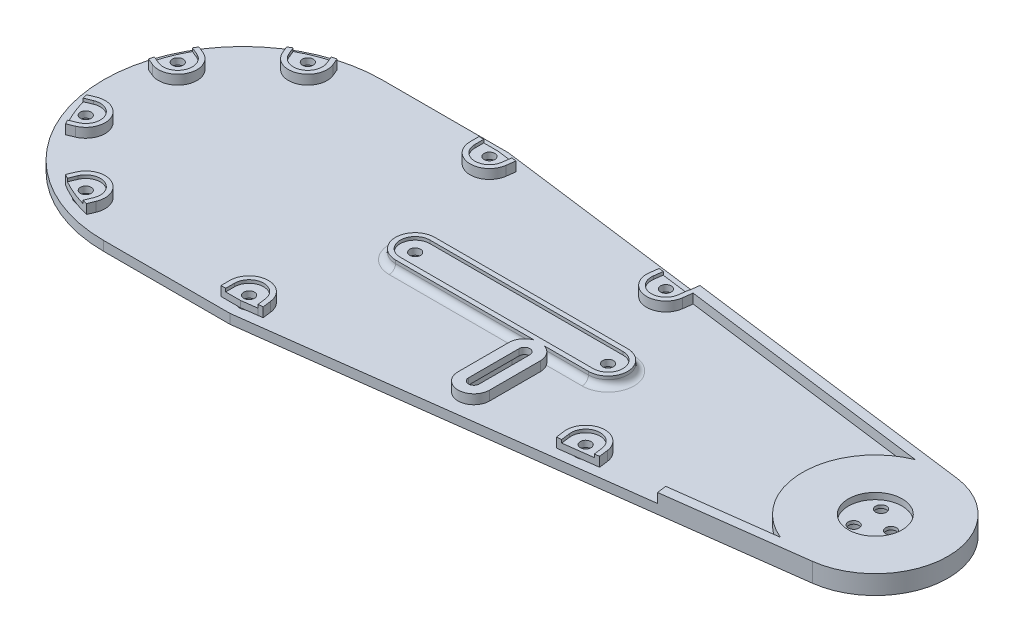
from build123d import *

# Parameters (mm, degrees)
SKETCH1_R               = 1.7
BOSS_EXTRUDE1_DEPTH     = 3
BOSS_EXTRUDE2_DEPTH     = 3
SKETCH3_R               = 1.7
BOSS_EXTRUDE3_DEPTH     = 2
SKETCH4_R               = 3
CUT_EXTRUDE1_DEPTH      = 3
SKETCH5_R               = 8.5
CUT_EXTRUDE2_DEPTH      = 1
SKETCH6_R               = 8.5
BOSS_EXTRUDE4_DEPTH     = 3
BOSS_EXTRUDE6_DEPTH     = 3
FILLET2_R               = 2
BOSS_EXTRUDE7_DEPTH     = 2
SKETCH9_R               = 1.7
CUT_EXTRUDE3_DEPTH      = 4
CUT_EXTRUDE3_DEPTH_BACK = 4
SKETCH11_R              = 3
CUT_EXTRUDE4_DEPTH      = 3
SKETCH12_R              = 8.5
BOSS_EXTRUDE8_DEPTH     = 2
CUT_EXTRUDE5_REACH      = 6
SKETCH13_R              = 1.7
SKETCH14_R              = 3
CUT_EXTRUDE6_DEPTH      = 3
CUT_EXTRUDE7_DEPTH      = 4
BOSS_EXTRUDE9_DEPTH     = 3
CUT_EXTRUDE8_DEPTH      = 4


with BuildPart() as part:
    # Sketch1 → Boss-Extrude1 (new body)
    with BuildSketch(Plane(origin=(0, 0, 0), x_dir=(1, 0, 0), z_dir=(0, 1, 0))):
        with BuildLine():
            Line((0, 44), (40, 44))
            Line((40, 44), (202.965939969, 22.807963524))
            ThreePointArc((202.965939969, 22.807963524), (223, 0), (202.965939969, -22.807963524))
            Line((202.965939969, -22.807963524), (40, -44))
            Line((40, -44), (0, -44))
            ThreePointArc((0, -44), (-44, 0), (0, 44))
        make_face()
        with Locations((-35.107422235, 14.54197043)):
            Circle(SKETCH1_R, mode=Mode.SUBTRACT)
        with Locations((-14.54197043, 35.107422235)):
            Circle(SKETCH1_R, mode=Mode.SUBTRACT)
        with Locations((-14.54197043, -35.107422235)):
            Circle(SKETCH1_R, mode=Mode.SUBTRACT)
        with Locations((-35.107422235, -14.54197043)):
            Circle(SKETCH1_R, mode=Mode.SUBTRACT)
        with Locations((40, 38)):
            Circle(SKETCH1_R, mode=Mode.SUBTRACT)
        with Locations((40, -38)):
            Circle(SKETCH1_R, mode=Mode.SUBTRACT)
        with Locations((134.1272378, -25.709207123)):
            Circle(SKETCH1_R, mode=Mode.SUBTRACT)
        with Locations((104.179390043, 29.603615256)):
            Circle(SKETCH1_R, mode=Mode.SUBTRACT)
    extrude(amount=BOSS_EXTRUDE1_DEPTH)

    # Sketch2 → Boss-Extrude2 (add)
    with BuildSketch(Plane(origin=(0, 3, 0), x_dir=(1, 0, 0), z_dir=(0, 1, 0))):
        with BuildLine():
            Line((-33.347078447, 18.791816279), (-35.693600281, 19.763777448))
            ThreePointArc((-35.693600281, 19.763777448), (-35.320993476, 20.422228573), (-34.936241394, 21.073657425))
            Line((-34.936241394, 21.073657425), (-32.773053298, 20.177635578))
            ThreePointArc((-32.773053298, 20.177635578), (-29.471757087, 12.207601492), (-37.441791173, 8.906305282))
            Line((-37.441791173, 8.906305282), (-39.604979269, 9.802327129))
            ThreePointArc((-39.604979269, 9.802327129), (-39.416410316, 10.535017694), (-39.214287859, 11.264085748))
            Line((-39.214287859, 11.264085748), (-36.867766024, 10.29212458))
            ThreePointArc((-36.867766024, 10.29212458), (-30.857576386, 12.781626641), (-33.347078447, 18.791816279))
        make_face()
        with BuildLine():
            Line((-20.177635578, 32.773053298), (-21.073657425, 34.936241394))
            ThreePointArc((-21.073657425, 34.936241394), (-20.422228573, 35.320993476), (-19.763777448, 35.693600281))
            Line((-19.763777448, 35.693600281), (-18.791816279, 33.347078447))
            ThreePointArc((-18.791816279, 33.347078447), (-12.781626641, 30.857576386), (-10.29212458, 36.867766024))
            Line((-10.29212458, 36.867766024), (-11.264085748, 39.214287859))
            ThreePointArc((-11.264085748, 39.214287859), (-10.535017694, 39.416410316), (-9.802327129, 39.604979269))
            Line((-9.802327129, 39.604979269), (-8.906305282, 37.441791173))
            ThreePointArc((-8.906305282, 37.441791173), (-12.207601492, 29.471757087), (-20.177635578, 32.773053298))
        make_face()
        with BuildLine():
            Line((-8.906305282, -37.441791173), (-9.802327129, -39.604979269))
            ThreePointArc((-9.802327129, -39.604979269), (-10.535017694, -39.416410316), (-11.264085748, -39.214287859))
            Line((-11.264085748, -39.214287859), (-10.29212458, -36.867766024))
            ThreePointArc((-10.29212458, -36.867766024), (-12.781626641, -30.857576386), (-18.791816279, -33.347078447))
            Line((-18.791816279, -33.347078447), (-19.763777448, -35.693600281))
            ThreePointArc((-19.763777448, -35.693600281), (-20.422228573, -35.320993476), (-21.073657425, -34.936241394))
            Line((-21.073657425, -34.936241394), (-20.177635578, -32.773053298))
            ThreePointArc((-20.177635578, -32.773053298), (-12.207601492, -29.471757087), (-8.906305282, -37.441791173))
        make_face()
        with BuildLine():
            Line((-32.773053298, -20.177635578), (-34.936241394, -21.073657425))
            ThreePointArc((-34.936241394, -21.073657425), (-35.320993476, -20.422228573), (-35.693600281, -19.763777448))
            Line((-35.693600281, -19.763777448), (-33.347078447, -18.791816279))
            ThreePointArc((-33.347078447, -18.791816279), (-30.857576386, -12.781626641), (-36.867766024, -10.29212458))
            Line((-36.867766024, -10.29212458), (-39.214287859, -11.264085748))
            ThreePointArc((-39.214287859, -11.264085748), (-39.416410316, -10.535017694), (-39.604979269, -9.802327129))
            Line((-39.604979269, -9.802327129), (-37.441791173, -8.906305282))
            ThreePointArc((-37.441791173, -8.906305282), (-29.471757087, -12.207601492), (-32.773053298, -20.177635578))
        make_face()
        with BuildLine():
            Line((44.561592705, 37.406812006), (44.916203521, 40.133755457))
            Line((44.916203521, 40.133755457), (46.403679403, 39.940324589))
            Line((46.403679403, 39.940324589), (46.049068587, 37.213381139))
            ThreePointArc((46.049068587, 37.213381139), (39.605867014, 31.91274617), (33.9, 38))
            Line((33.9, 38), (33.9, 40.8))
            Line((33.9, 40.8), (35.4, 40.8))
            Line((35.4, 40.8), (35.4, 38))
            ThreePointArc((35.4, 38), (39.702784962, 33.409611866), (44.561592705, 37.406812006))
        make_face()
        with BuildLine():
            Line((99.617797338, 30.19680325), (99.978868291, 32.973424896))
            Line((99.978868291, 32.973424896), (98.491392409, 33.166855764))
            Line((98.491392409, 33.166855764), (98.130321456, 30.390234117))
            ThreePointArc((98.130321456, 30.390234117), (103.392771182, 23.554546669), (110.22845863, 28.816996395))
            Line((110.22845863, 28.816996395), (110.589529583, 31.593618041))
            Line((110.589529583, 31.593618041), (109.102053701, 31.787048908))
            Line((109.102053701, 31.787048908), (108.740982748, 29.010427262))
            ThreePointArc((108.740982748, 29.010427262), (103.586202049, 25.042022551), (99.617797338, 30.19680325))
        make_face()
        with BuildLine():
            Line((129.565645096, -26.302395116), (129.926716048, -29.079016763))
            Line((129.926716048, -29.079016763), (128.439240166, -29.27244763))
            Line((128.439240166, -29.27244763), (128.078169214, -26.495825984))
            ThreePointArc((128.078169214, -26.495825984), (133.340618939, -19.660138536), (140.176306387, -24.922588261))
            Line((140.176306387, -24.922588261), (140.53737734, -27.699209908))
            Line((140.53737734, -27.699209908), (139.049901458, -27.892640775))
            Line((139.049901458, -27.892640775), (138.688830505, -25.116019129))
            ThreePointArc((138.688830505, -25.116019129), (133.534049807, -21.147614418), (129.565645096, -26.302395116))
        make_face()
        with BuildLine():
            Line((44.561592705, -37.406812006), (44.916203521, -40.133755457))
            Line((44.916203521, -40.133755457), (46.403679403, -39.940324589))
            Line((46.403679403, -39.940324589), (46.049068587, -37.213381139))
            ThreePointArc((46.049068587, -37.213381139), (39.605867014, -31.91274617), (33.9, -38))
            Line((33.9, -38), (33.9, -40.8))
            Line((33.9, -40.8), (35.4, -40.8))
            Line((35.4, -40.8), (35.4, -38))
            ThreePointArc((35.4, -38), (39.702784962, -33.409611866), (44.561592705, -37.406812006))
        make_face()
    extrude(amount=BOSS_EXTRUDE2_DEPTH)

    # Sketch3 → Boss-Extrude3 (add)
    with BuildSketch(Plane(origin=(0, 3, 0), x_dir=(1, 0, 0), z_dir=(0, 1, 0))):
        with BuildLine():
            Line((-36.867766024, 10.29212458), (-39.214287859, 11.264085748))
            ThreePointArc((-39.214287859, 11.264085748), (-37.694284926, 15.61348404), (-35.693600281, 19.763777448))
            Line((-35.693600281, 19.763777448), (-33.347078447, 18.791816279))
            ThreePointArc((-33.347078447, 18.791816279), (-30.857576386, 12.781626641), (-36.867766024, 10.29212458))
        make_face()
        with Locations((-35.107422235, 14.54197043)):
            Circle(SKETCH3_R, mode=Mode.SUBTRACT)
        with BuildLine():
            Line((-11.264085748, 39.214287859), (-10.29212458, 36.867766024))
            ThreePointArc((-10.29212458, 36.867766024), (-12.781626641, 30.857576386), (-18.791816279, 33.347078447))
            Line((-18.791816279, 33.347078447), (-19.763777448, 35.693600281))
            ThreePointArc((-19.763777448, 35.693600281), (-15.61348404, 37.694284926), (-11.264085748, 39.214287859))
        make_face()
        with Locations((-14.54197043, 35.107422235)):
            Circle(SKETCH3_R, mode=Mode.SUBTRACT)
        with BuildLine():
            Line((-19.763777448, -35.693600281), (-18.791816279, -33.347078447))
            ThreePointArc((-18.791816279, -33.347078447), (-12.781626641, -30.857576386), (-10.29212458, -36.867766024))
            Line((-10.29212458, -36.867766024), (-11.264085748, -39.214287859))
            ThreePointArc((-11.264085748, -39.214287859), (-15.61348404, -37.694284926), (-19.763777448, -35.693600281))
        make_face()
        with Locations((-14.54197043, -35.107422235)):
            Circle(SKETCH3_R, mode=Mode.SUBTRACT)
        with BuildLine():
            Line((-39.214287859, -11.264085748), (-36.867766024, -10.29212458))
            ThreePointArc((-36.867766024, -10.29212458), (-30.857576386, -12.781626641), (-33.347078447, -18.791816279))
            Line((-33.347078447, -18.791816279), (-35.693600281, -19.763777448))
            ThreePointArc((-35.693600281, -19.763777448), (-37.694284926, -15.61348404), (-39.214287859, -11.264085748))
        make_face()
        with Locations((-35.107422235, -14.54197043)):
            Circle(SKETCH3_R, mode=Mode.SUBTRACT)
        with BuildLine():
            Line((138.688830505, -25.116019129), (139.049901458, -27.892640775))
            Line((139.049901458, -27.892640775), (129.926716048, -29.079016763))
            Line((129.926716048, -29.079016763), (129.565645096, -26.302395116))
            ThreePointArc((129.565645096, -26.302395116), (133.534049807, -21.147614418), (138.688830505, -25.116019129))
        make_face()
        with Locations((134.1272378, -25.709207123)):
            Circle(SKETCH3_R, mode=Mode.SUBTRACT)
        with BuildLine():
            Line((109.102053701, 31.787048908), (108.740982748, 29.010427262))
            ThreePointArc((108.740982748, 29.010427262), (103.586202049, 25.042022551), (99.617797338, 30.19680325))
            Line((99.617797338, 30.19680325), (99.978868291, 32.973424896))
            Line((99.978868291, 32.973424896), (109.102053701, 31.787048908))
        make_face()
        with Locations((104.179390043, 29.603615256)):
            Circle(SKETCH3_R, mode=Mode.SUBTRACT)
        with BuildLine():
            Line((44.561592705, -37.406812006), (44.916203521, -40.133755457))
            Line((44.916203521, -40.133755457), (40, -40.8))
            Line((40, -40.8), (35.4, -40.8))
            Line((35.4, -40.8), (35.4, -38))
            ThreePointArc((35.4, -38), (39.702784962, -33.409611866), (44.561592705, -37.406812006))
        make_face()
        with Locations((40, -38)):
            Circle(SKETCH3_R, mode=Mode.SUBTRACT)
        with BuildLine():
            Line((44.916203521, 40.133755457), (44.561592705, 37.406812006))
            ThreePointArc((44.561592705, 37.406812006), (39.702784962, 33.409611866), (35.4, 38))
            Line((35.4, 38), (35.4, 40.8))
            Line((35.4, 40.8), (40, 40.8))
            Line((40, 40.8), (44.916203521, 40.133755457))
        make_face()
        with Locations((40, 38)):
            Circle(SKETCH3_R, mode=Mode.SUBTRACT)
    extrude(amount=BOSS_EXTRUDE3_DEPTH)

    # Sketch4 → Cut-Extrude1 (cut)
    with BuildSketch(Plane.XZ):
        with Locations((-14.54197043, 35.107422235)):
            Circle(SKETCH4_R)
        with Locations((-35.107422235, 14.54197043)):
            Circle(SKETCH4_R)
        with Locations((-35.107422235, -14.54197043)):
            Circle(SKETCH4_R)
        with Locations((-14.54197043, -35.107422235)):
            Circle(SKETCH4_R)
        with Locations((40, 38)):
            Circle(SKETCH4_R)
        with Locations((134.1272378, 25.709207123)):
            Circle(SKETCH4_R)
        with Locations((104.179390043, -29.603615256)):
            Circle(SKETCH4_R)
        with Locations((40, -38)):
            Circle(SKETCH4_R)
    extrude(amount=-CUT_EXTRUDE1_DEPTH, mode=Mode.SUBTRACT)

    # Sketch5 → Cut-Extrude2 (cut)
    with BuildSketch(Plane(origin=(0, 3, 0), x_dir=(1, 0, 0), z_dir=(0, 1, 0))):
        with Locations((200, 0)):
            Circle(SKETCH5_R)
    extrude(amount=-CUT_EXTRUDE2_DEPTH, mode=Mode.SUBTRACT)

    # Sketch6 → Boss-Extrude4 (add)
    with BuildSketch(Plane(origin=(0, 3, 0), x_dir=(1, 0, 0), z_dir=(0, 1, 0))):
        with BuildLine():
            Line((159.585349939, -28.449160982), (159.198488204, -25.474209218))
            Line((159.198488204, -25.474209218), (191.316092633, -21.29764665))
            ThreePointArc((191.316092633, -21.29764665), (177, 0), (191.316092633, 21.29764665))
            Line((191.316092633, 21.29764665), (110.615320365, 31.791948159))
            Line((110.615320365, 31.791948159), (110.589529583, 31.593618041))
            Line((110.589529583, 31.593618041), (109.102053701, 31.787048908))
            Line((109.102053701, 31.787048908), (109.127844483, 31.985379026))
            Line((109.127844483, 31.985379026), (109.227009542, 31.972483635))
            Line((109.227009542, 31.972483635), (109.613871277, 34.947435399))
            Line((109.613871277, 34.947435399), (202.965939969, 22.807963524))
            ThreePointArc((202.965939969, 22.807963524), (223, 0), (202.965939969, -22.807963524))
            Line((202.965939969, -22.807963524), (159.585349939, -28.449160982))
        make_face()
        with Locations((200, 0)):
            Circle(SKETCH6_R, mode=Mode.SUBTRACT)
    extrude(amount=BOSS_EXTRUDE4_DEPTH)

    # Sketch8 → Boss-Extrude6 (add)
    with BuildSketch(Plane(origin=(0, 3, 0), x_dir=(1, 0, 0), z_dir=(0, 1, 0))):
        with BuildLine():
            Line((54.5, 6.2), (115.5, 6.2))
            ThreePointArc((115.5, 6.2), (121.7, 0), (115.5, -6.2))
            Line((115.5, -6.2), (54.5, -6.2))
            ThreePointArc((54.5, -6.2), (48.3, 0), (54.5, 6.2))
        make_face()
        with BuildLine():
            Line((54.5, 4.7), (115.5, 4.7))
            ThreePointArc((115.5, 4.7), (120.2, 0), (115.5, -4.7))
            Line((115.5, -4.7), (54.5, -4.7))
            ThreePointArc((54.5, -4.7), (49.8, 0), (54.5, 4.7))
        make_face(mode=Mode.SUBTRACT)
    extrude(amount=BOSS_EXTRUDE6_DEPTH)

    # Fillet2
    fillet2_edges = [part.edges().sort_by_distance(p)[0] for p in [
        (48.3, 3, 0),
        (85, 3, 6.2),
        (121.7, 3, 0),
        (85, 3, -6.2),
    ]]
    fillet(fillet2_edges, radius=FILLET2_R)

    # Sketch10 → Boss-Extrude7 (add)
    with BuildSketch(Plane(origin=(0, 3, 0), x_dir=(1, 0, 0), z_dir=(0, 1, 0))):
        with BuildLine():
            Line((54.5, -4.7), (115.5, -4.7))
            ThreePointArc((115.5, -4.7), (120.2, 0), (115.5, 4.7))
            Line((115.5, 4.7), (54.5, 4.7))
            ThreePointArc((54.5, 4.7), (49.8, 0), (54.5, -4.7))
        make_face()
    extrude(amount=BOSS_EXTRUDE7_DEPTH)

    # Sketch9 → Cut-Extrude3 (cut, two sides)
    with BuildSketch(Plane(origin=(0, 3, 0), x_dir=(1, 0, 0), z_dir=(0, 1, 0))) as cut_extrude3_sk:
        with Locations((54.5, 0)):
            Circle(SKETCH9_R)
        with Locations((115.5, 0)):
            Circle(SKETCH9_R)
    extrude(amount=CUT_EXTRUDE3_DEPTH, mode=Mode.SUBTRACT)
    extrude(cut_extrude3_sk.sketch, amount=-CUT_EXTRUDE3_DEPTH_BACK, mode=Mode.SUBTRACT)

    # Sketch11 → Cut-Extrude4 (cut)
    with BuildSketch(Plane.XZ):
        with Locations((54.5, 0)):
            Circle(SKETCH11_R)
        with Locations((115.5, 0)):
            Circle(SKETCH11_R)
    extrude(amount=-CUT_EXTRUDE4_DEPTH, mode=Mode.SUBTRACT)

    # Sketch12 → Boss-Extrude8 (add)
    with BuildSketch(Plane(origin=(0, 2, 0), x_dir=(1, 0, 0), z_dir=(0, 1, 0))):
        with Locations((200, 0)):
            Circle(SKETCH12_R)
    extrude(amount=BOSS_EXTRUDE8_DEPTH)

    # Sketch13 → Cut-Extrude5 (cut, up to next)
    with BuildSketch(Plane(origin=(0, 4, 0), x_dir=(1, 0, 0), z_dir=(0, 1, 0)), mode=Mode.PRIVATE) as cut_extrude5_sk1:
        with Locations((205, 0)):
            Circle(SKETCH13_R)
    cut_extrude5_tool1 = extrude(cut_extrude5_sk1.sketch, amount=-CUT_EXTRUDE5_REACH, mode=Mode.PRIVATE) & part.part
    add(cut_extrude5_tool1.solids().sort_by_distance((205, 4, 0))[0], mode=Mode.SUBTRACT)
    # Sketch13 → Cut-Extrude5 (cut, up to next)
    with BuildSketch(Plane(origin=(0, 4, 0), x_dir=(1, 0, 0), z_dir=(0, 1, 0)), mode=Mode.PRIVATE) as cut_extrude5_sk2:
        with Locations((197.5, -4.330127019)):
            Circle(SKETCH13_R)
    cut_extrude5_tool2 = extrude(cut_extrude5_sk2.sketch, amount=-CUT_EXTRUDE5_REACH, mode=Mode.PRIVATE) & part.part
    add(cut_extrude5_tool2.solids().sort_by_distance((197.5, 4, 4.330127))[0], mode=Mode.SUBTRACT)
    # Sketch13 → Cut-Extrude5 (cut, up to next)
    with BuildSketch(Plane(origin=(0, 4, 0), x_dir=(1, 0, 0), z_dir=(0, 1, 0)), mode=Mode.PRIVATE) as cut_extrude5_sk3:
        with Locations((197.5, 4.330127019)):
            Circle(SKETCH13_R)
    cut_extrude5_tool3 = extrude(cut_extrude5_sk3.sketch, amount=-CUT_EXTRUDE5_REACH, mode=Mode.PRIVATE) & part.part
    add(cut_extrude5_tool3.solids().sort_by_distance((197.5, 4, -4.330127))[0], mode=Mode.SUBTRACT)

    # Sketch14 → Cut-Extrude6 (cut)
    with BuildSketch(Plane.XZ):
        with Locations((197.5, 4.330127019)):
            Circle(SKETCH14_R)
        with Locations((205, 0)):
            Circle(SKETCH14_R)
        with Locations((197.5, -4.330127019)):
            Circle(SKETCH14_R)
    extrude(amount=-CUT_EXTRUDE6_DEPTH, mode=Mode.SUBTRACT)

    # Sketch15 → Cut-Extrude7 (cut, through all)
    with BuildSketch(Plane(origin=(0, 3, 0), x_dir=(1, 0, 0), z_dir=(0, 1, 0))):
        with BuildLine():
            Line((101.7, -10.936180439), (101.7, -26.936180439))
            ThreePointArc((101.7, -26.936180439), (100, -28.636180439), (98.3, -26.936180439))
            Line((98.3, -26.936180439), (98.3, -10.936180439))
            ThreePointArc((98.3, -10.936180439), (100, -9.236180439), (101.7, -10.936180439))
        make_face()
    extrude(amount=-CUT_EXTRUDE7_DEPTH, mode=Mode.SUBTRACT)

    # Sketch16 → Boss-Extrude9 (add)
    with BuildSketch(Plane(origin=(0, 3, 0), x_dir=(1, 0, 0), z_dir=(0, 1, 0))):
        with BuildLine():
            Line((95, -10.936180439), (95, -26.936180439))
            ThreePointArc((95, -26.936180439), (100, -31.936180439), (105, -26.936180439))
            Line((105, -26.936180439), (105, -10.936180439))
            ThreePointArc((105, -10.936180439), (100, -5.936180439), (95, -10.936180439))
        make_face()
        with BuildLine():
            Line((98.3, -10.936180439), (98.3, -26.936180439))
            ThreePointArc((98.3, -26.936180439), (100, -28.636180439), (101.7, -26.936180439))
            Line((101.7, -26.936180439), (101.7, -10.936180439))
            ThreePointArc((101.7, -10.936180439), (100, -9.236180439), (98.3, -10.936180439))
        make_face(mode=Mode.SUBTRACT)
    extrude(amount=BOSS_EXTRUDE9_DEPTH)

    # Sketch17 → Cut-Extrude8 (cut)
    with BuildSketch(Plane.XZ):
        with BuildLine():
            Line((96, 26.936180439), (96, 10.936180439))
            ThreePointArc((96, 10.936180439), (100, 6.936180439), (104, 10.936180439))
            Line((104, 10.936180439), (104, 26.936180439))
            ThreePointArc((104, 26.936180439), (100, 30.936180439), (96, 26.936180439))
        make_face()
    extrude(amount=-CUT_EXTRUDE8_DEPTH, mode=Mode.SUBTRACT)


solid = part.part
